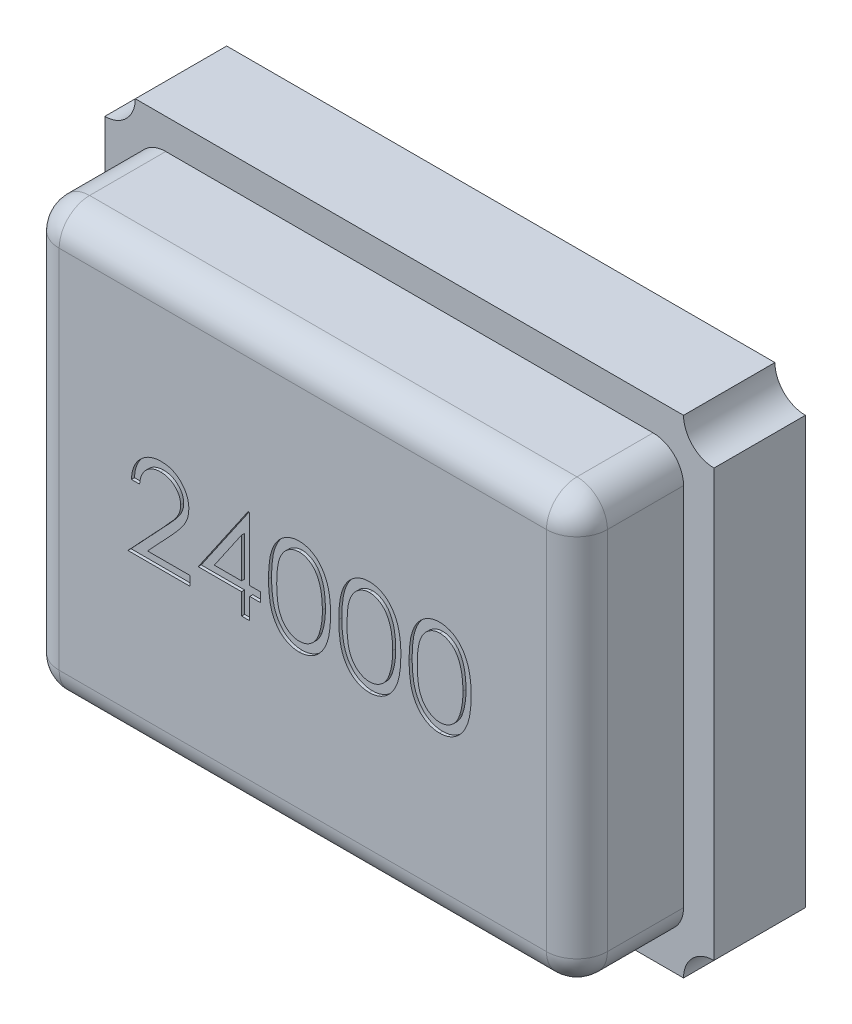
from build123d import *

# Parameters (mm, degrees)
EXTRUDE_1_DEPTH     = 0.3
EXTRUDE_2_DEPTH     = 0.35
FILLET_1_R          = 0.1
SKETCH_3_W          = 0.5
SKETCH_3_H          = 0.5
EXTRUDE_3_DEPTH     = 0.01
CUT_EXTRUDE_1_DEPTH = 0.01


with BuildPart() as part:
    # Эскиз1 → Бобышка-Вытянуть1 (new body)
    with BuildSketch(Plane.XY):
        with BuildLine():
            Line((-0.9, 0.8), (0.9, 0.8))
            ThreePointArc((0.9, 0.8), (0.929289322, 0.729289322), (1, 0.7))
            Line((1, 0.7), (1, -0.7))
            ThreePointArc((1, -0.7), (0.929289322, -0.729289322), (0.9, -0.8))
            Line((0.9, -0.8), (-0.9, -0.8))
            ThreePointArc((-0.9, -0.8), (-0.929289322, -0.729289322), (-1, -0.7))
            Line((-1, -0.7), (-1, 0.7))
            ThreePointArc((-1, 0.7), (-0.929289322, 0.729289322), (-0.9, 0.8))
        make_face()
    extrude(amount=EXTRUDE_1_DEPTH)

    # Эскиз2 → Бобышка-Вытянуть2 (add)
    with BuildSketch(Plane.XY.offset(0.3)):
        with BuildLine():
            Line((-0.8, 0.7), (0.8, 0.7))
            ThreePointArc((0.8, 0.7), (0.870710678, 0.670710678), (0.9, 0.6))
            Line((0.9, 0.6), (0.9, -0.6))
            ThreePointArc((0.9, -0.6), (0.870710678, -0.670710678), (0.8, -0.7))
            Line((0.8, -0.7), (-0.8, -0.7))
            ThreePointArc((-0.8, -0.7), (-0.870710678, -0.670710678), (-0.9, -0.6))
            Line((-0.9, -0.6), (-0.9, 0.6))
            ThreePointArc((-0.9, 0.6), (-0.870710678, 0.670710678), (-0.8, 0.7))
        make_face()
    extrude(amount=EXTRUDE_2_DEPTH)

    # Скругление1
    fillet_1_edges = [part.edges().sort_by_distance(p)[0] for p in [
        (-0.870710678, -0.670710678, 0.65),
        (0, -0.7, 0.65),
        (0.870710678, -0.670710678, 0.65),
        (0.9, 0, 0.65),
        (0.870710678, 0.670710678, 0.65),
        (0, 0.7, 0.65),
        (-0.870710678, 0.670710678, 0.65),
        (-0.9, 0, 0.65),
    ]]
    fillet(fillet_1_edges, radius=FILLET_1_R)

    # Эскиз3 → Бобышка-Вытянуть3 (add)
    with BuildSketch(Plane(origin=(0, 0, 0), x_dir=(-1, 0, 0), z_dir=(0, 0, -1))):
        with Locations((-0.65, 0.45)):
            Rectangle(SKETCH_3_W, SKETCH_3_H)
        Polygon((0.4, 0.7), (0.9, 0.7), (0.9, 0.2), (0.567705098, 0.2), (-0.4, -0.283852549), (-0.4, -0.7), (-0.9, -0.7), (-0.9, -0.2), (-0.567705098, -0.2), (0.4, 0.283852549), align=None)
        with Locations((0.65, -0.45)):
            Rectangle(SKETCH_3_W, SKETCH_3_H)
    extrude(amount=EXTRUDE_3_DEPTH)

    # Эскиз4 → Вырез-Вытянуть1 (cut)
    with BuildSketch(Plane.XY.offset(0.65)):
        with BuildLine():
            Line((-0.535786859, 0.061245593), (-0.562709936, 0.061245593))
            add(Edge.make_bspline(
                [(-0.562709936, 0.061245593), (-0.562534466, 0.064817383), (-0.562189847, 0.071832285), (-0.560575993, 0.082060048), (-0.558266775, 0.091836174), (-0.555001793, 0.101082166), (-0.55094697, 0.109879778), (-0.546084396, 0.118194065), (-0.540324923, 0.12599331), (-0.533792917, 0.133205211), (-0.526698462, 0.139821288), (-0.519043668, 0.145534595), (-0.510999808, 0.150361824), (-0.502591288, 0.154397359), (-0.49372324, 0.157426489), (-0.484476138, 0.159674058), (-0.474809355, 0.161026316), (-0.468223067, 0.161171669), (-0.464873397, 0.161245593)],
                knots=[0, 0, 0, 0, 1.10065271, 2.161652631, 3.183658789, 4.190468796, 5.17591951, 6.163126047, 7.15150782, 8.156236427, 9.156009102, 10.134482811, 11.092018607, 12.041330605, 13.001268258, 13.972401359, 14.968799086, 16, 16, 16, 16], degree=3))
            add(Edge.make_bspline(
                [(-0.464873397, 0.161245593), (-0.461583848, 0.161168582), (-0.455120001, 0.161017259), (-0.445686114, 0.159717743), (-0.436705204, 0.157682406), (-0.428194824, 0.154826799), (-0.420222875, 0.150988134), (-0.412729471, 0.146376916), (-0.405625402, 0.141043788), (-0.399230535, 0.13476489), (-0.393358414, 0.128061828), (-0.388292506, 0.120905722), (-0.383954235, 0.11351464), (-0.380338148, 0.105832223), (-0.377676193, 0.097786135), (-0.375655204, 0.089493518), (-0.374512854, 0.080868534), (-0.374337532, 0.075030829), (-0.374248397, 0.072062901)],
                knots=[0, 0, 0, 0, 1.111607364, 2.184268762, 3.212621178, 4.221274766, 5.211760367, 6.196651075, 7.1921475, 8.207485113, 9.220403448, 10.201281604, 11.166441695, 12.114753415, 13.065576456, 14.026450734, 14.996634279, 16, 16, 16, 16], degree=3))
            add(Edge.make_bspline(
                [(-0.374248397, 0.072062901), (-0.374393534, 0.067884515), (-0.374681261, 0.059601068), (-0.377142493, 0.047428365), (-0.38098648, 0.035634644), (-0.385614825, 0.026142875), (-0.390283891, 0.01849429), (-0.394491392, 0.012196972), (-0.399416947, 0.005416504), (-0.405132247, -0.001824411), (-0.411519065, -0.009582489), (-0.41863525, -0.017853043), (-0.426531548, -0.026550623), (-0.432073706, -0.032491103), (-0.434945513, -0.035569311)],
                knots=[0, 0, 0, 0, 1.184426356, 2.348067706, 3.509069118, 4.696110526, 5.333549288, 6.050745305, 6.844228056, 7.710549037, 8.667450064, 9.695053472, 10.805634456, 12, 12, 12, 12], degree=3))
            Line((-0.434945513, -0.035569311), (-0.510005609, -0.115677484))
            Line((-0.510005609, -0.115677484), (-0.370402243, -0.115677484))
            Line((-0.370402243, -0.115677484), (-0.370402243, -0.146446715))
            Line((-0.370402243, -0.146446715), (-0.574248397, -0.146446715))
            Line((-0.574248397, -0.146446715), (-0.457902243, -0.022288061))
            add(Edge.make_bspline(
                [(-0.457902243, -0.022288061), (-0.455069567, -0.019331063), (-0.449628577, -0.013651276), (-0.441932927, -0.005359022), (-0.435021014, 0.002333796), (-0.428848094, 0.009412643), (-0.42354808, 0.015981063), (-0.418844746, 0.021826323), (-0.415076266, 0.027205276), (-0.410986375, 0.033440186), (-0.407025177, 0.04105267), (-0.403621261, 0.050355558), (-0.401545702, 0.059932179), (-0.401296716, 0.066403783), (-0.401171474, 0.069659055)],
                knots=[0, 0, 0, 0, 1.329631726, 2.553950428, 3.673215718, 4.687767853, 5.603093632, 6.413772471, 7.123043292, 7.734684054, 8.834405432, 9.900288307, 10.943827018, 12, 12, 12, 12], degree=3))
            add(Edge.make_bspline(
                [(-0.401171474, 0.069659055), (-0.401225966, 0.071706032), (-0.40133336, 0.07574023), (-0.402281163, 0.081655009), (-0.403713492, 0.087360565), (-0.405765943, 0.092874447), (-0.408475092, 0.098141217), (-0.41177281, 0.103167286), (-0.415577673, 0.108026341), (-0.41997921, 0.112582338), (-0.424814483, 0.116755012), (-0.429922562, 0.120451363), (-0.435326856, 0.123540429), (-0.441004581, 0.126072729), (-0.446939907, 0.12805919), (-0.453144314, 0.12943564), (-0.459600658, 0.130299853), (-0.464009243, 0.130416782), (-0.466255609, 0.130476362)],
                knots=[0, 0, 0, 0, 0.991446411, 1.95395049, 2.89581595, 3.838931463, 4.798493298, 5.75982156, 6.748411868, 7.785213223, 8.824556874, 9.840280684, 10.836137867, 11.835679398, 12.848801643, 13.863922112, 14.911575587, 16, 16, 16, 16], degree=3))
            add(Edge.make_bspline(
                [(-0.466255609, 0.130476362), (-0.46860168, 0.130415074), (-0.473208977, 0.130294713), (-0.479973466, 0.129452771), (-0.486426532, 0.12800027), (-0.49258441, 0.126013698), (-0.498457517, 0.123488679), (-0.504017292, 0.120343673), (-0.509251254, 0.116590802), (-0.514169242, 0.112335897), (-0.51870044, 0.107598674), (-0.522681601, 0.10231782), (-0.526160231, 0.096589756), (-0.529195308, 0.090429937), (-0.531660081, 0.083782471), (-0.533543494, 0.076670953), (-0.535033795, 0.069126263), (-0.535531668, 0.063916113), (-0.535786859, 0.061245593)],
                knots=[0, 0, 0, 0, 1.031018746, 2.02475058, 2.990194455, 3.934040569, 4.864654155, 5.795059489, 6.735614925, 7.690564532, 8.649604399, 9.611025574, 10.590972636, 11.591080095, 12.624614302, 13.701020113, 14.821632451, 16, 16, 16, 16], degree=3))
        make_face()
        Polygon((-0.179717147, 0.161245593), (-0.174248397, 0.161245593), (-0.174248397, -0.046446715), (-0.139633013, -0.046446715), (-0.139633013, -0.077215945), (-0.174248397, -0.077215945), (-0.174248397, -0.146446715), (-0.201171474, -0.146446715), (-0.201171474, -0.077215945), (-0.343479167, -0.077215945), align=None)
        Polygon((-0.201171474, -0.046446715), (-0.201171474, 0.083841747), (-0.290594551, -0.046446715), align=None, mode=Mode.SUBTRACT)
        with BuildLine():
            add(Edge.make_bspline(
                [(-0.112709936, 0.003433093), (-0.11268182, 0.008241441), (-0.112627204, 0.017581725), (-0.112019626, 0.031191837), (-0.111010311, 0.043959862), (-0.109627107, 0.05588641), (-0.107943852, 0.066974562), (-0.10569681, 0.077194684), (-0.103141427, 0.086594078), (-0.100179789, 0.095203397), (-0.096837978, 0.103138629), (-0.093200756, 0.110546503), (-0.089123773, 0.117415811), (-0.084840038, 0.123856194), (-0.080176146, 0.129762224), (-0.075264821, 0.13521731), (-0.069914375, 0.140095374), (-0.064306688, 0.144539343), (-0.058390991, 0.148435012), (-0.052335906, 0.15186639), (-0.046099754, 0.154797807), (-0.03966551, 0.157102701), (-0.033091005, 0.159006488), (-0.026353256, 0.160308398), (-0.019441139, 0.161127561), (-0.014775588, 0.161205876), (-0.012409455, 0.161245593)],
                knots=[0, 0, 0, 0, 1.646270934, 3.197905019, 4.663502075, 6.030701355, 7.308322542, 8.50163776, 9.611534131, 10.641858119, 11.616356847, 12.558055219, 13.465016945, 14.349605745, 15.204443733, 16.039544428, 16.859896111, 17.680448484, 18.487036065, 19.28249412, 20.06191084, 20.843045899, 21.620316918, 22.403196591, 23.190181807, 24, 24, 24, 24], degree=3))
            add(Edge.make_bspline(
                [(-0.012409455, 0.161245593), (-0.010023557, 0.16120378), (-0.005278756, 0.161120628), (0.001736133, 0.160321433), (0.008588963, 0.158995337), (0.015250518, 0.157116396), (0.021775517, 0.154785338), (0.028112923, 0.151863585), (0.034302101, 0.148462539), (0.040244698, 0.144466207), (0.04600595, 0.140010583), (0.051444347, 0.134973783), (0.056560383, 0.129406664), (0.061418266, 0.12336879), (0.065880175, 0.116744354), (0.070129326, 0.109648573), (0.073932643, 0.101957356), (0.077595616, 0.093799031), (0.080757357, 0.08494786), (0.08360875, 0.075453738), (0.085912661, 0.065204522), (0.087831742, 0.054253986), (0.089318447, 0.042561916), (0.090401245, 0.030153375), (0.090973224, 0.017020199), (0.091080941, 0.008040954), (0.091136218, 0.003433093)],
                knots=[0, 0, 0, 0, 0.810914788, 1.612654377, 2.396697861, 3.181598691, 3.963628158, 4.749916497, 5.551656086, 6.361998678, 7.18212741, 8.025565596, 8.878627764, 9.750805457, 10.657531673, 11.591944965, 12.560506719, 13.57287815, 14.630710178, 15.753379473, 16.941251878, 18.199788006, 19.531962791, 20.947069417, 22.433333509, 24, 24, 24, 24], degree=3))
            add(Edge.make_bspline(
                [(0.091136218, 0.003433093), (0.091080368, -0.001154671), (0.090971546, -0.010093741), (0.090407657, -0.023167824), (0.089296917, -0.035510514), (0.08790749, -0.047151411), (0.085983122, -0.058042064), (0.083616964, -0.068220159), (0.080989794, -0.077729651), (0.077746812, -0.086492635), (0.074197322, -0.094631354), (0.070335448, -0.102231395), (0.066198034, -0.109359935), (0.061690428, -0.115959913), (0.056885849, -0.122078084), (0.051681468, -0.127606451), (0.046223989, -0.132678223), (0.040445782, -0.13719122), (0.034410506, -0.141141346), (0.028242585, -0.144673962), (0.021832581, -0.147522478), (0.015325756, -0.149968339), (0.008629039, -0.151836949), (0.001750777, -0.153128994), (-0.005274043, -0.154035152), (-0.010022749, -0.154104279), (-0.012409455, -0.154139022)],
                knots=[0, 0, 0, 0, 1.561518951, 3.042555995, 4.452378317, 5.7783523, 7.031515105, 8.214008947, 9.334062868, 10.386615937, 11.391082383, 12.354592575, 13.286541444, 14.194233754, 15.072674879, 15.931287219, 16.775624067, 17.606195743, 18.42308326, 19.229000347, 20.022332153, 20.807536673, 21.593273796, 22.3848459, 23.188221202, 24, 24, 24, 24], degree=3))
            add(Edge.make_bspline(
                [(-0.012409455, -0.154139022), (-0.014775522, -0.154099049), (-0.019440944, -0.154020229), (-0.026354009, -0.153204767), (-0.033063933, -0.151893724), (-0.039603826, -0.150058015), (-0.046007242, -0.147811029), (-0.052186923, -0.14488357), (-0.058211582, -0.141512079), (-0.064065144, -0.137672471), (-0.069637615, -0.13327347), (-0.074960352, -0.128407959), (-0.07989964, -0.122954524), (-0.084496848, -0.116999273), (-0.088866055, -0.110596995), (-0.092885145, -0.103660278), (-0.096602646, -0.096216625), (-0.10000066, -0.088217947), (-0.103013402, -0.079547525), (-0.105674635, -0.070106167), (-0.107775848, -0.059810541), (-0.109574387, -0.048743338), (-0.111025049, -0.036857001), (-0.112015419, -0.024145077), (-0.112627532, -0.010615488), (-0.112681967, -0.001335221), (-0.112709936, 0.003433093)],
                knots=[0, 0, 0, 0, 0.810891512, 1.598919785, 2.382837074, 3.152667961, 3.926044502, 4.706494248, 5.493654104, 6.291793342, 7.103789334, 7.925228297, 8.761435821, 9.622817696, 10.50288917, 11.416980706, 12.369136599, 13.353924996, 14.394355917, 15.514179734, 16.714354668, 17.994756427, 19.357759367, 20.818452758, 22.365282078, 24, 24, 24, 24], degree=3))
        make_face()
        with BuildLine():
            add(Edge.make_bspline(
                [(-0.085786859, 0.003553285), (-0.085776621, -0.000453746), (-0.08575675, -0.008230607), (-0.085237647, -0.019531458), (-0.084530484, -0.030071772), (-0.083618373, -0.039864932), (-0.082263835, -0.04887779), (-0.08074611, -0.057172335), (-0.078899131, -0.064704669), (-0.076713844, -0.071526482), (-0.074224778, -0.077753545), (-0.071507133, -0.083547934), (-0.068587642, -0.0889781), (-0.065320286, -0.093995267), (-0.061761852, -0.098615795), (-0.057992716, -0.102921467), (-0.053872209, -0.106761208), (-0.048171888, -0.111366367), (-0.040646476, -0.11612515), (-0.031164723, -0.1202691), (-0.021421712, -0.122873311), (-0.014808748, -0.12320449), (-0.011508013, -0.123369792)],
                knots=[0, 0, 0, 0, 1.459021318, 2.831673884, 4.118529203, 5.306027144, 6.411944654, 7.436330062, 8.375795394, 9.233974572, 10.042671642, 10.816086306, 11.563610507, 12.285937304, 12.993564865, 13.685989202, 14.367179055, 15.041617293, 16.353048772, 17.594441528, 18.799311195, 20, 20, 20, 20], degree=3))
            add(Edge.make_bspline(
                [(-0.011508013, -0.123369792), (-0.008185927, -0.123232839), (-0.001548613, -0.122959216), (0.008148569, -0.120319325), (0.017562592, -0.116336221), (0.024940187, -0.111626435), (0.030552977, -0.10714115), (0.034574433, -0.103317037), (0.038265466, -0.099035106), (0.041766215, -0.094415166), (0.044976993, -0.089368953), (0.047896691, -0.083920732), (0.050560977, -0.078055374), (0.052078896, -0.073960825), (0.052854968, -0.071867388)],
                knots=[0, 0, 0, 0, 1.353760809, 2.704726607, 4.075137775, 5.516104923, 6.260822281, 7.007110065, 7.778089737, 8.566572457, 9.372053459, 10.217411131, 11.088608312, 12, 12, 12, 12], degree=3))
            add(Edge.make_bspline(
                [(0.052854968, -0.071867388), (0.053759405, -0.069190553), (0.055595801, -0.06375543), (0.057962524, -0.05532426), (0.059826416, -0.046478309), (0.061503276, -0.037270442), (0.062647823, -0.027632753), (0.063569064, -0.017595063), (0.064111695, -0.007149803), (0.064178959, -5.309e-05), (0.064213141, 0.003553285)],
                knots=[0, 0, 0, 0, 0.884706709, 1.796334032, 2.740027952, 3.714592787, 4.726048262, 5.777819803, 6.87074269, 8, 8, 8, 8], degree=3))
            add(Edge.make_bspline(
                [(0.064213141, 0.003553285), (0.064165982, 0.007159077), (0.064073729, 0.014212777), (0.063721101, 0.024542907), (0.062810509, 0.034354429), (0.061799156, 0.043689613), (0.060307966, 0.052496781), (0.058700154, 0.060849665), (0.05654005, 0.068644781), (0.054232641, 0.076004174), (0.05159175, 0.08284423), (0.048684687, 0.08919684), (0.045579964, 0.095092674), (0.042207772, 0.100515554), (0.038608142, 0.105489772), (0.034686067, 0.109915595), (0.030597121, 0.113930192), (0.024869933, 0.118512698), (0.017372137, 0.123185129), (0.00804251, 0.127485051), (-0.001666402, 0.129954334), (-0.008229841, 0.130302478), (-0.011508013, 0.130476362)],
                knots=[0, 0, 0, 0, 1.31362396, 2.569729283, 3.763502607, 4.902122613, 5.988968491, 7.01645872, 7.998833611, 8.933434873, 9.825090667, 10.667526885, 11.477055099, 12.250526234, 12.991942729, 13.710640831, 14.402115721, 15.076753259, 16.378508321, 17.609869233, 18.806226677, 20, 20, 20, 20], degree=3))
            add(Edge.make_bspline(
                [(-0.011508013, 0.130476362), (-0.014826063, 0.130302238), (-0.02146821, 0.129953673), (-0.031278034, 0.127494251), (-0.040681264, 0.123207426), (-0.048159234, 0.118497222), (-0.053890415, 0.114011081), (-0.057926075, 0.110120814), (-0.061710032, 0.105865421), (-0.065195835, 0.101202399), (-0.068460631, 0.096191082), (-0.071459004, 0.090792045), (-0.074160489, 0.084977928), (-0.076653449, 0.078753662), (-0.078845402, 0.071932438), (-0.080653456, 0.064409382), (-0.082323775, 0.05614122), (-0.083506227, 0.047079548), (-0.084557406, 0.037283934), (-0.08523295, 0.026717307), (-0.085758486, 0.015397503), (-0.085777212, 0.007580432), (-0.085786859, 0.003553285)],
                knots=[0, 0, 0, 0, 1.207732386, 2.417664972, 3.655092373, 4.956220595, 5.625982001, 6.301752483, 6.994047911, 7.697131622, 8.419323945, 9.170223765, 9.943494443, 10.752040957, 11.610060368, 12.549350801, 13.567764191, 14.679664412, 15.874934091, 17.154273443, 18.533957287, 20, 20, 20, 20], degree=3))
        make_face(mode=Mode.SUBTRACT)
        with BuildLine():
            add(Edge.make_bspline(
                [(0.118059295, 0.003433093), (0.118087411, 0.008241441), (0.118142026, 0.017581725), (0.118749605, 0.031191837), (0.11975892, 0.043959862), (0.121142124, 0.05588641), (0.122825379, 0.066974562), (0.125072421, 0.077194684), (0.127627804, 0.086594078), (0.130589442, 0.095203397), (0.133931253, 0.103138629), (0.137568475, 0.110546503), (0.141645457, 0.117415811), (0.145929193, 0.123856194), (0.150593085, 0.129762224), (0.155504409, 0.13521731), (0.160854856, 0.140095374), (0.166462542, 0.144539343), (0.172378239, 0.148435012), (0.178433325, 0.15186639), (0.184669477, 0.154797807), (0.191103721, 0.157102701), (0.197678226, 0.159006488), (0.204415975, 0.160308398), (0.211328092, 0.161127561), (0.215993643, 0.161205876), (0.218359776, 0.161245593)],
                knots=[0, 0, 0, 0, 1.646270934, 3.197905019, 4.663502075, 6.030701355, 7.308322542, 8.50163776, 9.611534131, 10.641858119, 11.616356847, 12.558055219, 13.465016945, 14.349605745, 15.204443733, 16.039544428, 16.859896111, 17.680448484, 18.487036065, 19.28249412, 20.06191084, 20.843045899, 21.620316918, 22.403196591, 23.190181807, 24, 24, 24, 24], degree=3))
            add(Edge.make_bspline(
                [(0.218359776, 0.161245593), (0.220745674, 0.16120378), (0.225490475, 0.161120628), (0.232505364, 0.160321433), (0.239358194, 0.158995337), (0.246019749, 0.157116396), (0.252544747, 0.154785338), (0.258882154, 0.151863585), (0.265071332, 0.148462539), (0.271013928, 0.144466207), (0.276775181, 0.140010583), (0.282213578, 0.134973783), (0.287329614, 0.129406664), (0.292187497, 0.12336879), (0.296649405, 0.116744354), (0.300898557, 0.109648573), (0.304701874, 0.101957356), (0.308364846, 0.093799031), (0.311526588, 0.08494786), (0.31437798, 0.075453738), (0.316681892, 0.065204522), (0.318600973, 0.054253986), (0.320087678, 0.042561916), (0.321170476, 0.030153375), (0.321742455, 0.017020199), (0.321850172, 0.008040954), (0.321905449, 0.003433093)],
                knots=[0, 0, 0, 0, 0.810914788, 1.612654377, 2.396697861, 3.181598691, 3.963628158, 4.749916497, 5.551656086, 6.361998678, 7.18212741, 8.025565596, 8.878627764, 9.750805457, 10.657531673, 11.591944965, 12.560506719, 13.57287815, 14.630710178, 15.753379473, 16.941251878, 18.199788006, 19.531962791, 20.947069417, 22.433333509, 24, 24, 24, 24], degree=3))
            add(Edge.make_bspline(
                [(0.321905449, 0.003433093), (0.321849599, -0.001154671), (0.321740777, -0.010093741), (0.321176888, -0.023167824), (0.320066148, -0.035510514), (0.318676721, -0.047151411), (0.316752352, -0.058042064), (0.314386195, -0.068220159), (0.311759025, -0.077729651), (0.308516042, -0.086492635), (0.304966553, -0.094631354), (0.301104679, -0.102231395), (0.296967265, -0.109359935), (0.292459659, -0.115959913), (0.28765508, -0.122078084), (0.282450698, -0.127606451), (0.27699322, -0.132678223), (0.271215013, -0.13719122), (0.265179737, -0.141141346), (0.259011816, -0.144673962), (0.252601812, -0.147522478), (0.246094987, -0.149968339), (0.23939827, -0.151836949), (0.232520008, -0.153128994), (0.225495188, -0.154035152), (0.220746482, -0.154104279), (0.218359776, -0.154139022)],
                knots=[0, 0, 0, 0, 1.561518951, 3.042555995, 4.452378317, 5.7783523, 7.031515105, 8.214008947, 9.334062868, 10.386615937, 11.391082383, 12.354592575, 13.286541444, 14.194233754, 15.072674879, 15.931287219, 16.775624067, 17.606195743, 18.42308326, 19.229000347, 20.022332153, 20.807536673, 21.593273796, 22.3848459, 23.188221202, 24, 24, 24, 24], degree=3))
            add(Edge.make_bspline(
                [(0.218359776, -0.154139022), (0.215993709, -0.154099049), (0.211328287, -0.154020229), (0.204415222, -0.153204767), (0.197705298, -0.151893724), (0.191165405, -0.150058015), (0.184761989, -0.147811029), (0.178582307, -0.14488357), (0.172557649, -0.141512079), (0.166704087, -0.137672471), (0.161131616, -0.13327347), (0.155808878, -0.128407959), (0.150869591, -0.122954524), (0.146272383, -0.116999273), (0.141903175, -0.110596995), (0.137884086, -0.103660278), (0.134166584, -0.096216625), (0.130768571, -0.088217947), (0.127755828, -0.079547525), (0.125094596, -0.070106167), (0.122993383, -0.059810541), (0.121194844, -0.048743338), (0.119744182, -0.036857001), (0.118753811, -0.024145077), (0.118141699, -0.010615488), (0.118087264, -0.001335221), (0.118059295, 0.003433093)],
                knots=[0, 0, 0, 0, 0.810891512, 1.598919785, 2.382837074, 3.152667961, 3.926044502, 4.706494248, 5.493654104, 6.291793342, 7.103789334, 7.925228297, 8.761435821, 9.622817696, 10.50288917, 11.416980706, 12.369136599, 13.353924996, 14.394355917, 15.514179734, 16.714354668, 17.994756427, 19.357759367, 20.818452758, 22.365282078, 24, 24, 24, 24], degree=3))
        make_face()
        with BuildLine():
            add(Edge.make_bspline(
                [(0.144982372, 0.003553285), (0.14499261, -0.000453746), (0.145012481, -0.008230607), (0.145531584, -0.019531458), (0.146238746, -0.030071772), (0.147150858, -0.039864932), (0.148505396, -0.04887779), (0.150023121, -0.057172335), (0.1518701, -0.064704669), (0.154055387, -0.071526482), (0.156544453, -0.077753545), (0.159262098, -0.083547934), (0.162181589, -0.0889781), (0.165448944, -0.093995267), (0.169007378, -0.098615795), (0.172776515, -0.102921467), (0.176897022, -0.106761208), (0.182597343, -0.111366367), (0.190122755, -0.11612515), (0.199604508, -0.1202691), (0.209347518, -0.122873311), (0.215960483, -0.12320449), (0.219261218, -0.123369792)],
                knots=[0, 0, 0, 0, 1.459021318, 2.831673884, 4.118529203, 5.306027144, 6.411944654, 7.436330062, 8.375795394, 9.233974572, 10.042671642, 10.816086306, 11.563610507, 12.285937304, 12.993564865, 13.685989202, 14.367179055, 15.041617293, 16.353048772, 17.594441528, 18.799311195, 20, 20, 20, 20], degree=3))
            add(Edge.make_bspline(
                [(0.219261218, -0.123369792), (0.222583304, -0.123232839), (0.229220618, -0.122959216), (0.2389178, -0.120319325), (0.248331823, -0.116336221), (0.255709418, -0.111626435), (0.261322208, -0.10714115), (0.265343664, -0.103317037), (0.269034697, -0.099035106), (0.272535446, -0.094415166), (0.275746224, -0.089368953), (0.278665921, -0.083920732), (0.281330208, -0.078055374), (0.282848126, -0.073960825), (0.283624199, -0.071867388)],
                knots=[0, 0, 0, 0, 1.353760809, 2.704726607, 4.075137775, 5.516104923, 6.260822281, 7.007110065, 7.778089737, 8.566572457, 9.372053459, 10.217411131, 11.088608312, 12, 12, 12, 12], degree=3))
            add(Edge.make_bspline(
                [(0.283624199, -0.071867388), (0.284528636, -0.069190553), (0.286365032, -0.06375543), (0.288731755, -0.05532426), (0.290595646, -0.046478309), (0.292272506, -0.037270442), (0.293417054, -0.027632753), (0.294338295, -0.017595063), (0.294880925, -0.007149803), (0.29494819, -5.309e-05), (0.294982372, 0.003553285)],
                knots=[0, 0, 0, 0, 0.884706709, 1.796334032, 2.740027952, 3.714592787, 4.726048262, 5.777819803, 6.87074269, 8, 8, 8, 8], degree=3))
            add(Edge.make_bspline(
                [(0.294982372, 0.003553285), (0.294935213, 0.007159077), (0.29484296, 0.014212777), (0.294490332, 0.024542907), (0.29357974, 0.034354429), (0.292568387, 0.043689613), (0.291077197, 0.052496781), (0.289469385, 0.060849665), (0.287309281, 0.068644781), (0.285001871, 0.076004174), (0.28236098, 0.08284423), (0.279453917, 0.08919684), (0.276349195, 0.095092674), (0.272977003, 0.100515554), (0.269377373, 0.105489772), (0.265455298, 0.109915595), (0.261366351, 0.113930192), (0.255639164, 0.118512698), (0.248141368, 0.123185129), (0.238811741, 0.127485051), (0.229102828, 0.129954334), (0.222539389, 0.130302478), (0.219261218, 0.130476362)],
                knots=[0, 0, 0, 0, 1.31362396, 2.569729283, 3.763502607, 4.902122613, 5.988968491, 7.01645872, 7.998833611, 8.933434873, 9.825090667, 10.667526885, 11.477055099, 12.250526234, 12.991942729, 13.710640831, 14.402115721, 15.076753259, 16.378508321, 17.609869233, 18.806226677, 20, 20, 20, 20], degree=3))
            add(Edge.make_bspline(
                [(0.219261218, 0.130476362), (0.215943167, 0.130302238), (0.209301021, 0.129953673), (0.199491196, 0.127494251), (0.190087966, 0.123207426), (0.182609997, 0.118497222), (0.176878815, 0.114011081), (0.172843156, 0.110120814), (0.169059198, 0.105865421), (0.165573395, 0.101202399), (0.1623086, 0.096191082), (0.159310227, 0.090792045), (0.156608742, 0.084977928), (0.154115782, 0.078753662), (0.151923828, 0.071932438), (0.150115774, 0.064409382), (0.148445455, 0.05614122), (0.147263004, 0.047079548), (0.146211825, 0.037283934), (0.145536281, 0.026717307), (0.145010744, 0.015397503), (0.144992019, 0.007580432), (0.144982372, 0.003553285)],
                knots=[0, 0, 0, 0, 1.207732386, 2.417664972, 3.655092373, 4.956220595, 5.625982001, 6.301752483, 6.994047911, 7.697131622, 8.419323945, 9.170223765, 9.943494443, 10.752040957, 11.610060368, 12.549350801, 13.567764191, 14.679664412, 15.874934091, 17.154273443, 18.533957287, 20, 20, 20, 20], degree=3))
        make_face(mode=Mode.SUBTRACT)
        with BuildLine():
            add(Edge.make_bspline(
                [(0.348828526, 0.003433093), (0.348856642, 0.008241441), (0.348911257, 0.017581725), (0.349518836, 0.031191837), (0.350528151, 0.043959862), (0.351911354, 0.05588641), (0.35359461, 0.066974562), (0.355841652, 0.077194684), (0.358397035, 0.086594078), (0.361358673, 0.095203397), (0.364700483, 0.103138629), (0.368337706, 0.110546503), (0.372414688, 0.117415811), (0.376698423, 0.123856194), (0.381362315, 0.129762224), (0.38627364, 0.13521731), (0.391624087, 0.140095374), (0.397231773, 0.144539343), (0.40314747, 0.148435012), (0.409202556, 0.15186639), (0.415438708, 0.154797807), (0.421872952, 0.157102701), (0.428447457, 0.159006488), (0.435185206, 0.160308398), (0.442097322, 0.161127561), (0.446762874, 0.161205876), (0.449129007, 0.161245593)],
                knots=[0, 0, 0, 0, 1.646270934, 3.197905019, 4.663502075, 6.030701355, 7.308322542, 8.50163776, 9.611534131, 10.641858119, 11.616356847, 12.558055219, 13.465016945, 14.349605745, 15.204443733, 16.039544428, 16.859896111, 17.680448484, 18.487036065, 19.28249412, 20.06191084, 20.843045899, 21.620316918, 22.403196591, 23.190181807, 24, 24, 24, 24], degree=3))
            add(Edge.make_bspline(
                [(0.449129007, 0.161245593), (0.451514905, 0.16120378), (0.456259705, 0.161120628), (0.463274595, 0.160321433), (0.470127425, 0.158995337), (0.476788979, 0.157116396), (0.483313978, 0.154785338), (0.489651385, 0.151863585), (0.495840563, 0.148462539), (0.501783159, 0.144466207), (0.507544412, 0.140010583), (0.512982809, 0.134973783), (0.518098845, 0.129406664), (0.522956728, 0.12336879), (0.527418636, 0.116744354), (0.531667788, 0.109648573), (0.535471105, 0.101957356), (0.539134077, 0.093799031), (0.542295819, 0.08494786), (0.545147211, 0.075453738), (0.547451123, 0.065204522), (0.549370203, 0.054253986), (0.550856909, 0.042561916), (0.551939707, 0.030153375), (0.552511685, 0.017020199), (0.552619403, 0.008040954), (0.55267468, 0.003433093)],
                knots=[0, 0, 0, 0, 0.810914788, 1.612654377, 2.396697861, 3.181598691, 3.963628158, 4.749916497, 5.551656086, 6.361998678, 7.18212741, 8.025565596, 8.878627764, 9.750805457, 10.657531673, 11.591944965, 12.560506719, 13.57287815, 14.630710178, 15.753379473, 16.941251878, 18.199788006, 19.531962791, 20.947069417, 22.433333509, 24, 24, 24, 24], degree=3))
            add(Edge.make_bspline(
                [(0.55267468, 0.003433093), (0.55261883, -0.001154671), (0.552510008, -0.010093741), (0.551946119, -0.023167824), (0.550835379, -0.035510514), (0.549445951, -0.047151411), (0.547521583, -0.058042064), (0.545155426, -0.068220159), (0.542528255, -0.077729651), (0.539285273, -0.086492635), (0.535735784, -0.094631354), (0.53187391, -0.102231395), (0.527736496, -0.109359935), (0.523228889, -0.115959913), (0.518424311, -0.122078084), (0.513219929, -0.127606451), (0.50776245, -0.132678223), (0.501984243, -0.13719122), (0.495948968, -0.141141346), (0.489781047, -0.144673962), (0.483371042, -0.147522478), (0.476864218, -0.149968339), (0.470167501, -0.151836949), (0.463289239, -0.153128994), (0.456264418, -0.154035152), (0.451515713, -0.154104279), (0.449129007, -0.154139022)],
                knots=[0, 0, 0, 0, 1.561518951, 3.042555995, 4.452378317, 5.7783523, 7.031515105, 8.214008947, 9.334062868, 10.386615937, 11.391082383, 12.354592575, 13.286541444, 14.194233754, 15.072674879, 15.931287219, 16.775624067, 17.606195743, 18.42308326, 19.229000347, 20.022332153, 20.807536673, 21.593273796, 22.3848459, 23.188221202, 24, 24, 24, 24], degree=3))
            add(Edge.make_bspline(
                [(0.449129007, -0.154139022), (0.44676294, -0.154099049), (0.442097518, -0.154020229), (0.435184452, -0.153204767), (0.428474529, -0.151893724), (0.421934636, -0.150058015), (0.41553122, -0.147811029), (0.409351538, -0.14488357), (0.40332688, -0.141512079), (0.397473318, -0.137672471), (0.391900847, -0.13327347), (0.386578109, -0.128407959), (0.381638822, -0.122954524), (0.377041614, -0.116999273), (0.372672406, -0.110596995), (0.368653317, -0.103660278), (0.364935815, -0.096216625), (0.361537802, -0.088217947), (0.358525059, -0.079547525), (0.355863827, -0.070106167), (0.353762613, -0.059810541), (0.351964074, -0.048743338), (0.350513413, -0.036857001), (0.349523042, -0.024145077), (0.34891093, -0.010615488), (0.348856495, -0.001335221), (0.348828526, 0.003433093)],
                knots=[0, 0, 0, 0, 0.810891512, 1.598919785, 2.382837074, 3.152667961, 3.926044502, 4.706494248, 5.493654104, 6.291793342, 7.103789334, 7.925228297, 8.761435821, 9.622817696, 10.50288917, 11.416980706, 12.369136599, 13.353924996, 14.394355917, 15.514179734, 16.714354668, 17.994756427, 19.357759367, 20.818452758, 22.365282078, 24, 24, 24, 24], degree=3))
        make_face()
        with BuildLine():
            add(Edge.make_bspline(
                [(0.375751603, 0.003553285), (0.375761841, -0.000453746), (0.375781712, -0.008230607), (0.376300814, -0.019531458), (0.377007977, -0.030071772), (0.377920088, -0.039864932), (0.379274627, -0.04887779), (0.380792352, -0.057172335), (0.382639331, -0.064704669), (0.384824618, -0.071526482), (0.387313683, -0.077753545), (0.390031329, -0.083547934), (0.392950819, -0.0889781), (0.396218175, -0.093995267), (0.399776609, -0.098615795), (0.403545746, -0.102921467), (0.407666253, -0.106761208), (0.413366574, -0.111366367), (0.420891986, -0.11612515), (0.430373739, -0.1202691), (0.440116749, -0.122873311), (0.446729713, -0.12320449), (0.450030449, -0.123369792)],
                knots=[0, 0, 0, 0, 1.459021318, 2.831673884, 4.118529203, 5.306027144, 6.411944654, 7.436330062, 8.375795394, 9.233974572, 10.042671642, 10.816086306, 11.563610507, 12.285937304, 12.993564865, 13.685989202, 14.367179055, 15.041617293, 16.353048772, 17.594441528, 18.799311195, 20, 20, 20, 20], degree=3))
            add(Edge.make_bspline(
                [(0.450030449, -0.123369792), (0.453352535, -0.123232839), (0.459989848, -0.122959216), (0.469687031, -0.120319325), (0.479101054, -0.116336221), (0.486478649, -0.111626435), (0.492091438, -0.10714115), (0.496112895, -0.103317037), (0.499803927, -0.099035106), (0.503304677, -0.094415166), (0.506515455, -0.089368953), (0.509435152, -0.083920732), (0.512099439, -0.078055374), (0.513617357, -0.073960825), (0.51439343, -0.071867388)],
                knots=[0, 0, 0, 0, 1.353760809, 2.704726607, 4.075137775, 5.516104923, 6.260822281, 7.007110065, 7.778089737, 8.566572457, 9.372053459, 10.217411131, 11.088608312, 12, 12, 12, 12], degree=3))
            add(Edge.make_bspline(
                [(0.51439343, -0.071867388), (0.515297867, -0.069190553), (0.517134262, -0.06375543), (0.519500986, -0.05532426), (0.521364877, -0.046478309), (0.523041737, -0.037270442), (0.524186285, -0.027632753), (0.525107526, -0.017595063), (0.525650156, -0.007149803), (0.525717421, -5.309e-05), (0.525751603, 0.003553285)],
                knots=[0, 0, 0, 0, 0.884706709, 1.796334032, 2.740027952, 3.714592787, 4.726048262, 5.777819803, 6.87074269, 8, 8, 8, 8], degree=3))
            add(Edge.make_bspline(
                [(0.525751603, 0.003553285), (0.525704444, 0.007159077), (0.52561219, 0.014212777), (0.525259563, 0.024542907), (0.524348971, 0.034354429), (0.523337618, 0.043689613), (0.521846427, 0.052496781), (0.520238615, 0.060849665), (0.518078511, 0.068644781), (0.515771102, 0.076004174), (0.513130211, 0.08284423), (0.510223148, 0.08919684), (0.507118426, 0.095092674), (0.503746234, 0.100515554), (0.500146604, 0.105489772), (0.496224528, 0.109915595), (0.492135582, 0.113930192), (0.486408395, 0.118512698), (0.478910598, 0.123185129), (0.469580972, 0.127485051), (0.459872059, 0.129954334), (0.45330862, 0.130302478), (0.450030449, 0.130476362)],
                knots=[0, 0, 0, 0, 1.31362396, 2.569729283, 3.763502607, 4.902122613, 5.988968491, 7.01645872, 7.998833611, 8.933434873, 9.825090667, 10.667526885, 11.477055099, 12.250526234, 12.991942729, 13.710640831, 14.402115721, 15.076753259, 16.378508321, 17.609869233, 18.806226677, 20, 20, 20, 20], degree=3))
            add(Edge.make_bspline(
                [(0.450030449, 0.130476362), (0.446712398, 0.130302238), (0.440070252, 0.129953673), (0.430260427, 0.127494251), (0.420857197, 0.123207426), (0.413379228, 0.118497222), (0.407648046, 0.114011081), (0.403612387, 0.110120814), (0.399828429, 0.105865421), (0.396342626, 0.101202399), (0.39307783, 0.096191082), (0.390079458, 0.090792045), (0.387377973, 0.084977928), (0.384885012, 0.078753662), (0.382693059, 0.071932438), (0.380885005, 0.064409382), (0.379214686, 0.05614122), (0.378032235, 0.047079548), (0.376981056, 0.037283934), (0.376305511, 0.026717307), (0.375779975, 0.015397503), (0.37576125, 0.007580432), (0.375751603, 0.003553285)],
                knots=[0, 0, 0, 0, 1.207732386, 2.417664972, 3.655092373, 4.956220595, 5.625982001, 6.301752483, 6.994047911, 7.697131622, 8.419323945, 9.170223765, 9.943494443, 10.752040957, 11.610060368, 12.549350801, 13.567764191, 14.679664412, 15.874934091, 17.154273443, 18.533957287, 20, 20, 20, 20], degree=3))
        make_face(mode=Mode.SUBTRACT)
    extrude(amount=-CUT_EXTRUDE_1_DEPTH, mode=Mode.SUBTRACT)


solid = part.part
